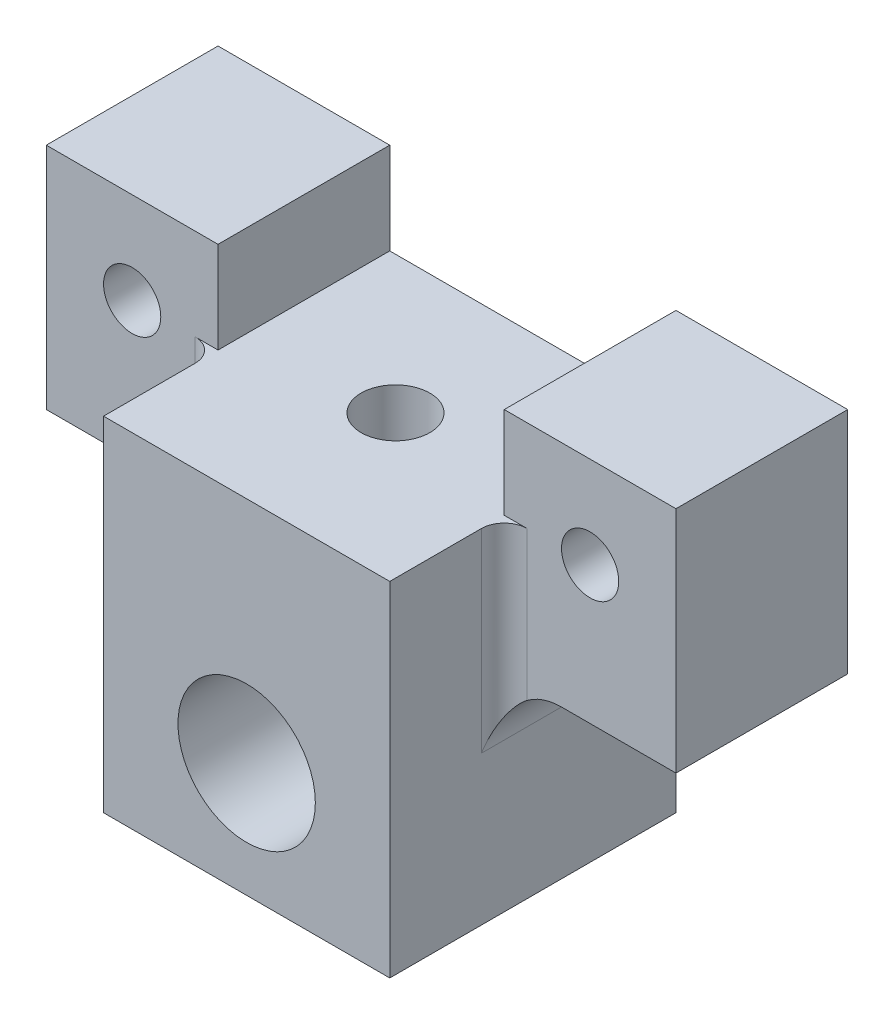
from build123d import *

# Parameters (mm, degrees)
SKETCH1_W                = 25
SKETCH1_H                = 25
BOSS_EXTRUDE1_DEPTH      = 30
SKETCH6_W                = 15
SKETCH6_H                = 15
BOSS_EXTRUDE2_DEPTH      = 8
BOSS_EXTRUDE2_DEPTH_BACK = 12
SKETCH3_R                = 2.5
CUT_EXTRUDE1_DEPTH       = 13.5
CUT_EXTRUDE1_DEPTH_BACK  = 13.5
SKETCH5_R                = 6
CUT_EXTRUDE4_DEPTH       = 11
SKETCH2_R                = 3
CUT_EXTRUDE6_DEPTH       = 31
SKETCH4_R                = 4.25
CUT_EXTRUDE3_DEPTH       = 17.5
FILLET1_R                = 5
FILLET2_R                = 2


with BuildPart() as part:
    # Sketch1 → Boss-Extrude1 (new body)
    with BuildSketch(Plane(origin=(0, 0, 0), x_dir=(1, 0, 0), z_dir=(0, 1, 0))):
        Rectangle(SKETCH1_W, SKETCH1_H)
    extrude(amount=-BOSS_EXTRUDE1_DEPTH)

    # Sketch6 → Boss-Extrude2 (add, two sides)
    with BuildSketch(Plane(origin=(0, 0, 0), x_dir=(1, 0, 0), z_dir=(0, 1, 0))) as boss_extrude2_sk:
        with Locations((20, 5)):
            Rectangle(SKETCH6_W, SKETCH6_H)
        with Locations((-20, 5)):
            Rectangle(SKETCH6_W, SKETCH6_H)
    extrude(amount=BOSS_EXTRUDE2_DEPTH)
    extrude(boss_extrude2_sk.sketch, amount=-BOSS_EXTRUDE2_DEPTH_BACK)

    # Sketch3 → Cut-Extrude1 (cut, two sides)
    with BuildSketch(Plane.XY) as cut_extrude1_sk:
        with Locations((0, -20)):
            Circle(SKETCH3_R)
        with Locations((20, 0)):
            Circle(SKETCH3_R)
        with Locations((-20, 0)):
            Circle(SKETCH3_R)
    extrude(amount=CUT_EXTRUDE1_DEPTH, mode=Mode.SUBTRACT)
    extrude(cut_extrude1_sk.sketch, amount=-CUT_EXTRUDE1_DEPTH_BACK, mode=Mode.SUBTRACT)

    # Sketch5 → Cut-Extrude4 (cut)
    with BuildSketch(Plane.XY.offset(12.5)):
        with Locations((0, -20)):
            Circle(SKETCH5_R)
    extrude(amount=-CUT_EXTRUDE4_DEPTH, mode=Mode.SUBTRACT)

    # Sketch2 → Cut-Extrude6 (cut, through all)
    with BuildSketch(Plane(origin=(0, 0, 0), x_dir=(1, 0, 0), z_dir=(0, 1, 0))):
        with Locations((0, 0.5)):
            Circle(SKETCH2_R)
    extrude(amount=-CUT_EXTRUDE6_DEPTH, mode=Mode.SUBTRACT)

    # Sketch4 → Cut-Extrude3 (cut)
    with BuildSketch(Plane.XZ.offset(30)):
        with Locations((0, -0.5)):
            Circle(SKETCH4_R)
    extrude(amount=-CUT_EXTRUDE3_DEPTH, mode=Mode.SUBTRACT)

    # Fillet1
    fillet1_edges = [part.edges().sort_by_distance(p)[0] for p in [
        (12.5, -12, -5),
        (-12.5, -12, -5),
    ]]
    fillet(fillet1_edges, radius=FILLET1_R)

    # Fillet2
    fillet2_edges = [part.edges().sort_by_distance(p)[0] for p in [
        (12.5, -6, 2.5),
        (-12.5, -6, 2.5),
    ]]
    fillet(fillet2_edges, radius=FILLET2_R)


solid = part.part
